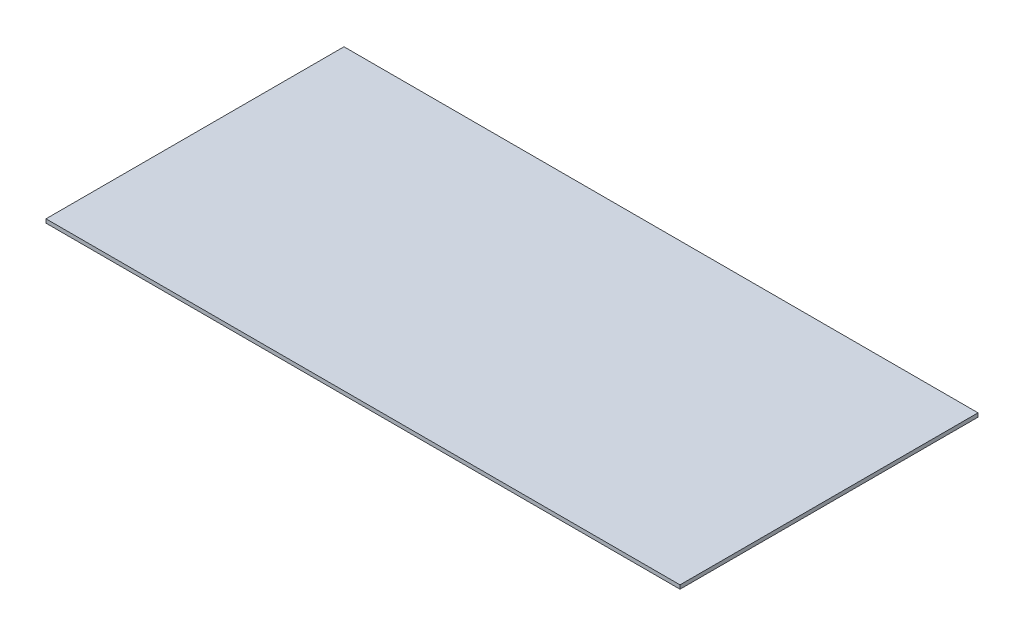
from build123d import *

# Parameters (mm, degrees)
BOSS_EXTRUDE1_DEPTH = 3


with BuildPart() as part:
    # Sketch1 → Boss-Extrude1 (new body)
    with BuildSketch(Plane(origin=(0, 0, 0), x_dir=(1, 0, 0), z_dir=(0, 1, 0))):
        Polygon((170, 117.5), (250, 117.5), (250, -117.5), (-250, -117.5), (-250, 117.5), align=None)
    extrude(amount=BOSS_EXTRUDE1_DEPTH)


solid = part.part
